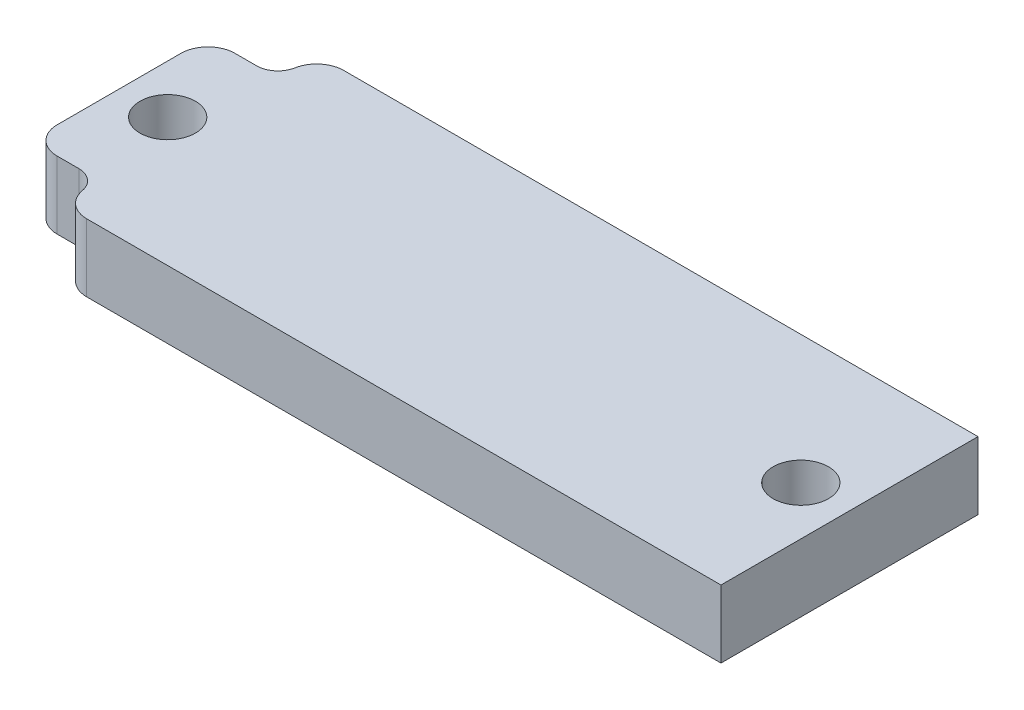
from build123d import *

# Parameters (mm, degrees)
SKETCH2_W           = 68.58
SKETCH2_H           = 24.13
SKETCH2_R           = 2.6
BOSS_EXTRUDE1_DEPTH = 6.35
CUT_EXTRUDE1_DEPTH  = 7.35
FILLET3_R           = 2.54


with BuildPart() as part:
    # Sketch2 → Boss-Extrude1 (new body)
    with BuildSketch(Plane(origin=(0, 0, 0), x_dir=(1, 0, 0), z_dir=(0, 1, 0))):
        with Locations((34.29, 12.065)):
            Rectangle(SKETCH2_W, SKETCH2_H)
        with Locations((4.57, 12.065)):
            Circle(SKETCH2_R, mode=Mode.SUBTRACT)
        with Locations((64.01, 12.065)):
            Circle(SKETCH2_R, mode=Mode.SUBTRACT)
    extrude(amount=BOSS_EXTRUDE1_DEPTH)

    # Sketch3 → Cut-Extrude1 (cut, through all)
    with BuildSketch(Plane(origin=(0, 6.35, 0), x_dir=(1, 0, 0), z_dir=(0, 1, 0))):
        with BuildLine():
            Line((4.57, 3.715), (0, 3.715))
            Line((0, 3.715), (0, 0))
            Line((0, 0), (6.57, 0))
            Line((6.57, 0), (6.57, 1.715))
            ThreePointArc((6.57, 1.715), (5.984213562, 3.129213562), (4.57, 3.715))
        make_face()
        with BuildLine():
            ThreePointArc((4.57, 20.415), (5.984213562, 21.000786438), (6.57, 22.415))
            Line((6.57, 22.415), (6.57, 24.13))
            Line((6.57, 24.13), (0, 24.13))
            Line((0, 24.13), (0, 20.415))
            Line((0, 20.415), (4.57, 20.415))
        make_face()
    extrude(amount=-CUT_EXTRUDE1_DEPTH, mode=Mode.SUBTRACT)

    # Fillet3
    fillet3_edges = [part.edges().sort_by_distance(p)[0] for p in [
        (6.57, 3.175, 0),
        (0, 3.175, -3.715),
        (0, 3.175, -20.415),
        (6.57, 3.175, -24.13),
    ]]
    fillet(fillet3_edges, radius=FILLET3_R)


solid = part.part
